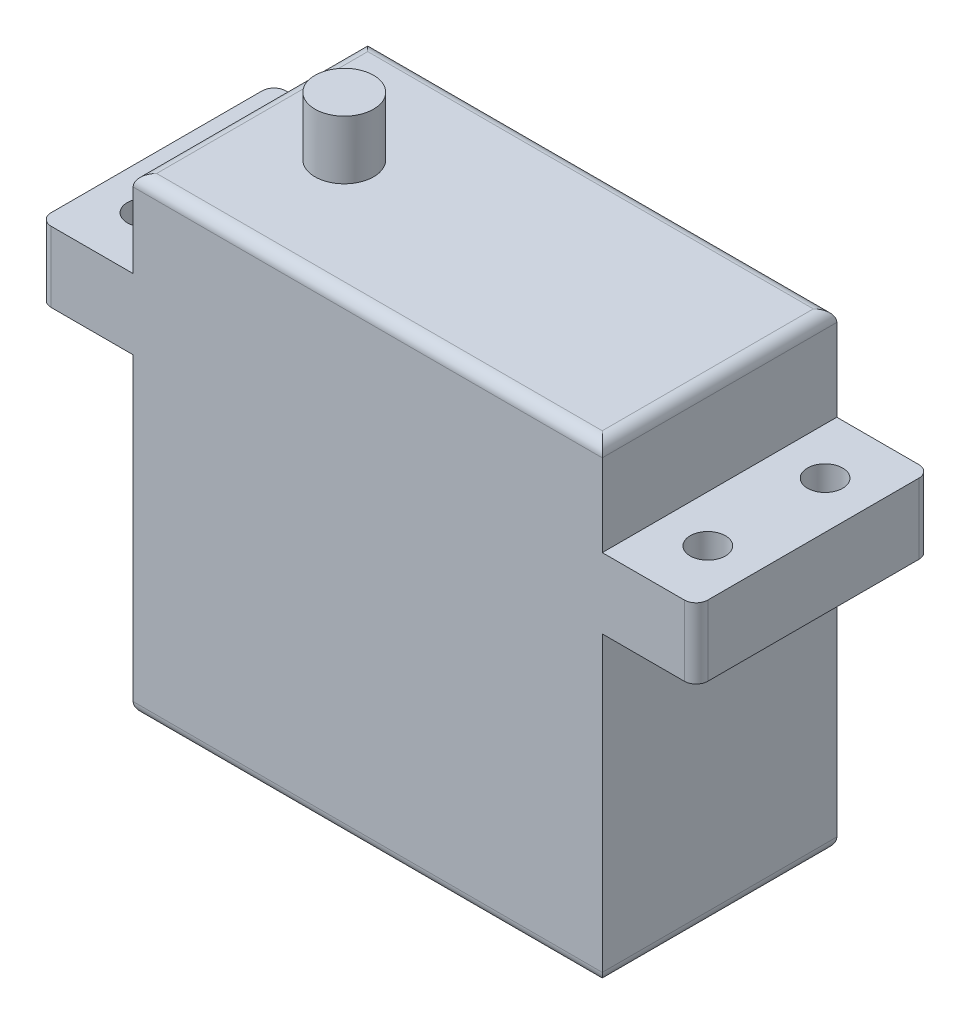
from build123d import *

# Parameters (mm, degrees)
IZIM1_W                     = 40
IZIM1_H                     = 40
Y_KSEKLIK_EKSTR_ZYON1_DEPTH = 20
IZIM2_W                     = 20
IZIM2_H                     = 6
Y_KSEKLIK_EKSTR_ZYON2_DEPTH = 8
IZIM3_W                     = 20
IZIM3_H                     = 6
Y_KSEKLIK_EKSTR_ZYON3_DEPTH = 8
IZIM4_R                     = 2.5
Y_KSEKLIK_EKSTR_ZYON4_DEPTH = 5
IZIM5_R                     = 1.5
KES_EKSTR_ZYON1_DEPTH       = 15
RADYUS1_R                   = 1
RADYUS2_R                   = 1
RADYUS3_R                   = 1
RADYUS4_R                   = 1
RADYUS5_R                   = 1


with BuildPart() as part:
    # Çizim1 → Yükseklik-Ekstrüzyon1 (new body)
    with BuildSketch(Plane.XY):
        Rectangle(IZIM1_W, IZIM1_H)
    extrude(amount=Y_KSEKLIK_EKSTR_ZYON1_DEPTH)

    # Çizim2 → Yükseklik-Ekstrüzyon2 (add)
    with BuildSketch(Plane(origin=(20, 0, 0), x_dir=(0, 0, -1), z_dir=(1, 0, 0))):
        with Locations((-10, 9)):
            Rectangle(IZIM2_W, IZIM2_H)
    extrude(amount=Y_KSEKLIK_EKSTR_ZYON2_DEPTH)

    # Çizim3 → Yükseklik-Ekstrüzyon3 (add)
    with BuildSketch(Plane.ZY.offset(20)):
        with Locations((10, 9.60422947)):
            Rectangle(IZIM3_W, IZIM3_H)
    extrude(amount=Y_KSEKLIK_EKSTR_ZYON3_DEPTH)

    # Çizim4 → Yükseklik-Ekstrüzyon4 (add)
    with BuildSketch(Plane(origin=(0, 20, 0), x_dir=(1, 0, 0), z_dir=(0, 1, 0))):
        with Locations((-12, -10)):
            Circle(IZIM4_R)
    extrude(amount=Y_KSEKLIK_EKSTR_ZYON4_DEPTH)

    # Çizim5 → Kes-Ekstrüzyon1 (cut)
    with BuildSketch(Plane(origin=(0, 12.60422947, 0), x_dir=(1, 0, 0), z_dir=(0, 1, 0))):
        with Locations((-24, -5)):
            Circle(IZIM5_R)
        with Locations((-24, -15)):
            Circle(IZIM5_R)
        with Locations((24, -15)):
            Circle(IZIM5_R)
        with Locations((24, -5)):
            Circle(IZIM5_R)
    extrude(amount=-KES_EKSTR_ZYON1_DEPTH, mode=Mode.SUBTRACT)

    # Radyus1
    radyus1_edges = [part.edges().sort_by_distance(p)[0] for p in [
        (0, 20, 0),
        (-20, 20, 10),
        (20, 20, 10),
        (0, 20, 20),
    ]]
    fillet(radyus1_edges, radius=RADYUS1_R)

    # Radyus2
    radyus2_edges = [part.edges().sort_by_distance(p)[0] for p in [
        (0, -20, 20),
        (0, -20, 0),
        (20, -20, 10),
        (-20, -20, 10),
    ]]
    fillet(radyus2_edges, radius=RADYUS2_R)

    # Radyus3
    radyus3_edges = [part.edges().sort_by_distance(p)[0] for p in [
        (28, 9, 20),
    ]]
    fillet(radyus3_edges, radius=RADYUS3_R)

    # Radyus4
    radyus4_edges = [part.edges().sort_by_distance(p)[0] for p in [
        (-28, 9.60422947, 0),
    ]]
    fillet(radyus4_edges, radius=RADYUS4_R)

    # Radyus5
    radyus5_edges = [part.edges().sort_by_distance(p)[0] for p in [
        (28, 9, 0),
        (-28, 9.60422947, 20),
    ]]
    fillet(radyus5_edges, radius=RADYUS5_R)


solid = part.part
